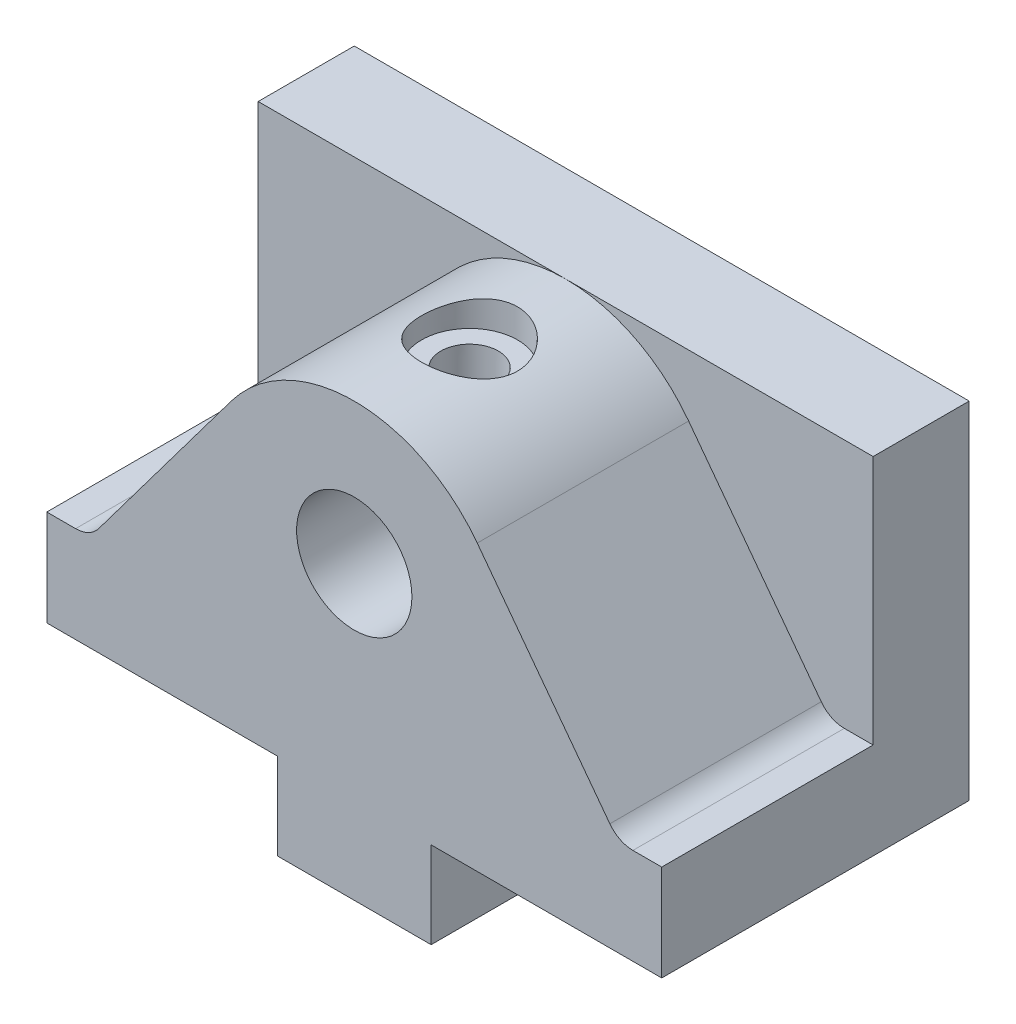
from build123d import *

# Parameters (mm, degrees)
SKETCH2_W           = 64
SKETCH2_H           = 32
BOSS_EXTRUDE1_DEPTH = 5
SKETCH3_W           = 64
SKETCH3_H           = 10
BOSS_EXTRUDE2_DEPTH = 36
SKETCH4_W           = 64
SKETCH4_H           = 22
BOSS_EXTRUDE3_DEPTH = 10
BOSS_EXTRUDE4_DEPTH = 22
CUT_EXTRUDE1_DEPTH  = 33
SKETCH7_R           = 6
CUT_EXTRUDE2_DEPTH  = 24
LPATTERN1_COUNT     = 2
LPATTERN1_PITCH     = 16
FILLET1_R           = 3


with BuildPart() as part:
    # Sketch2 → Boss-Extrude1 (new body, symmetric)
    with BuildSketch(Plane(origin=(0, 0, 0), x_dir=(1, 0, 0), z_dir=(0, 1, 0))):
        Rectangle(SKETCH2_W, SKETCH2_H)
    extrude(amount=BOSS_EXTRUDE1_DEPTH, both=True)

    # Sketch3 → Boss-Extrude2 (add)
    with BuildSketch(Plane(origin=(0, 5, 0), x_dir=(1, 0, 0), z_dir=(0, 1, 0))):
        with Locations((0, 11)):
            Rectangle(SKETCH3_W, SKETCH3_H)
    extrude(amount=BOSS_EXTRUDE2_DEPTH)

    # Sketch4 → Boss-Extrude3 (add)
    with BuildSketch(Plane(origin=(0, 5, 0), x_dir=(1, 0, 0), z_dir=(0, 1, 0))):
        with Locations((0, -5)):
            Rectangle(SKETCH4_W, SKETCH4_H)
    extrude(amount=BOSS_EXTRUDE3_DEPTH)

    # Sketch5 → Boss-Extrude4 (add)
    with BuildSketch(Plane.XY.offset(16)):
        with BuildLine():
            Line((-27.5, 15), (27.5, 15))
            Line((27.5, 15), (12.8, 34.6))
            ThreePointArc((12.8, 34.6), (0, 41), (-12.8, 34.6))
            Line((-12.8, 34.6), (-27.5, 15))
        make_face()
    extrude(amount=-BOSS_EXTRUDE4_DEPTH)

    # Sketch6 → Cut-Extrude1 (cut)
    with BuildSketch(Plane.XY.offset(16)):
        Polygon((-32, 5), (-32, -5), (32, -5), (32, 5), (8, 5), (8, -4), (-8, -4), (-8, 5), align=None)
    extrude(amount=-CUT_EXTRUDE1_DEPTH, mode=Mode.SUBTRACT)

    # Sketch7 → Cut-Extrude2 (cut)
    with BuildSketch(Plane.XY.offset(16)):
        with Locations((0, 26.35)):
            Circle(SKETCH7_R)
    extrude(amount=-CUT_EXTRUDE2_DEPTH, mode=Mode.SUBTRACT)

    # Sketch10 → Cut-Revolve2 (revolve, cut)
    with BuildSketch(Plane.XY.offset(8)):
        Polygon((0, -4), (0, 13), (3, 12), (3, -4), align=None)
    cut_revolve2 = revolve(axis=Axis((0, -4, 8), (0, 1, 0)), mode=Mode.SUBTRACT)

    # LPattern1: Cut-Revolve2 ×2
    with Locations(*[(0, 0, -i * LPATTERN1_PITCH) for i in range(1, LPATTERN1_COUNT)]):
        add(cut_revolve2, mode=Mode.SUBTRACT)

    # Sketch15 → Cut-Revolve4 (revolve, cut)
    with BuildSketch(Plane(origin=(0, 0, 4), x_dir=(-1, 0, 0), z_dir=(0, 0, -1))):
        Polygon((-0.003619483, 30.011523803), (0, 41), (4.996380517, 41.011523803), (4.996380517, 38.011523803), (2.996380517, 38.011523803), (2.996380517, 31.011523803), align=None)
    revolve(axis=Axis((0.003619483, 30.011523803, 4), (-0.000329389, 0.999999946, 0)), mode=Mode.SUBTRACT)

    # Fillet1
    fillet1_edges = [part.edges().sort_by_distance(p)[0] for p in [
        (27.5, 15, 5),
        (-27.5, 15, 5),
    ]]
    fillet(fillet1_edges, radius=FILLET1_R)


solid = part.part
